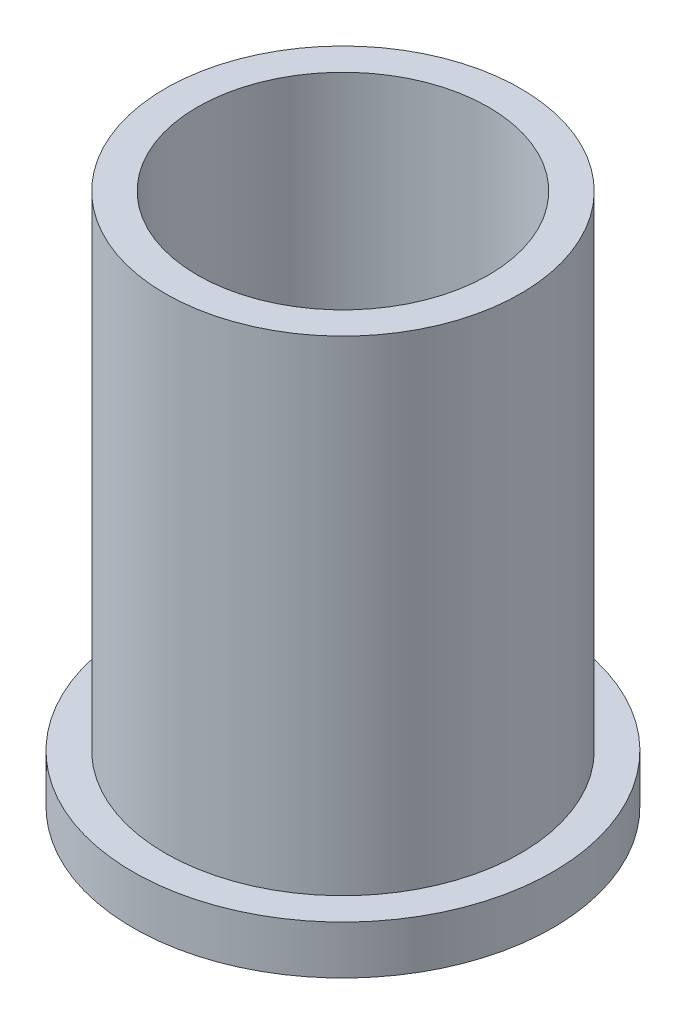
from build123d import *

# Parameters (mm, degrees)
SKETCH1_R           = 55
SKETCH1_R_2         = 45.05
BOSS_EXTRUDE1_DEPTH = 150
SKETCH2_R           = 65
BOSS_EXTRUDE2_DEPTH = 15


with BuildPart() as part:
    # Sketch1 → Boss-Extrude1 (new body)
    with BuildSketch(Plane(origin=(0, 0, 0), x_dir=(1, 0, 0), z_dir=(0, 1, 0))):
        Circle(SKETCH1_R)
        Circle(SKETCH1_R_2, mode=Mode.SUBTRACT)
    extrude(amount=BOSS_EXTRUDE1_DEPTH)

    # Sketch2 → Boss-Extrude2 (add)
    with BuildSketch(Plane.XZ):
        Circle(SKETCH2_R)
    extrude(amount=BOSS_EXTRUDE2_DEPTH)


solid = part.part
